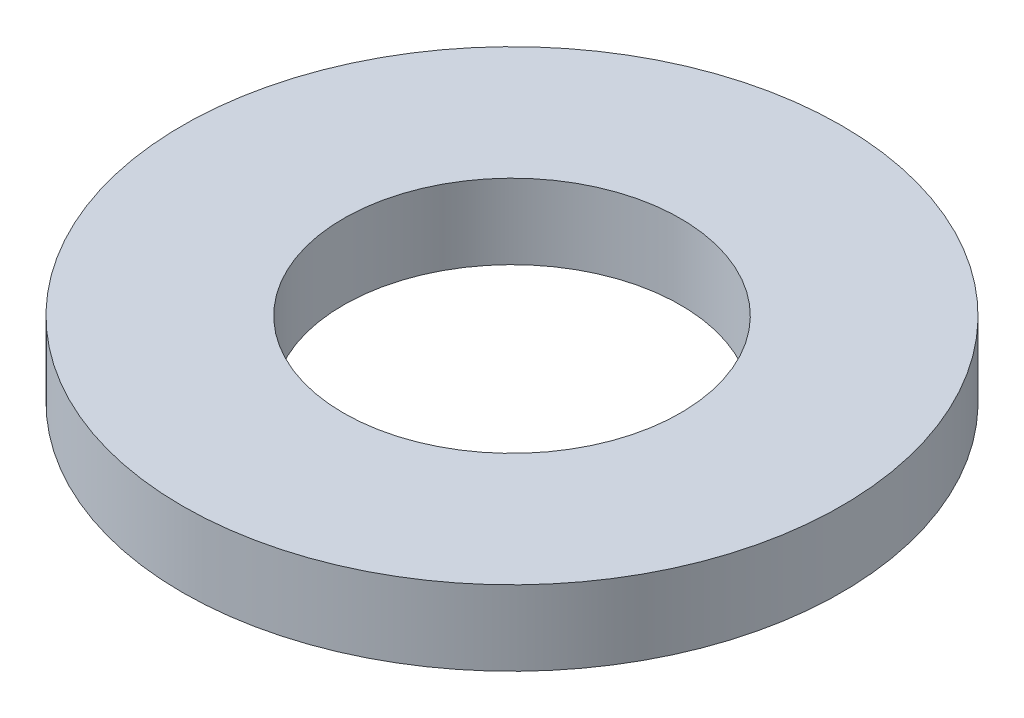
from build123d import *

# Parameters (mm, degrees)
SKETCH_1_R      = 4.4
SKETCH_1_R_2    = 2.25
EXTRUDE_1_DEPTH = 1


with BuildPart() as part:
    # 草图1 → 凸台-拉伸1 (new body)
    with BuildSketch(Plane(origin=(0, 0, 0), x_dir=(1, 0, 0), z_dir=(0, 1, 0))):
        Circle(SKETCH_1_R)
        Circle(SKETCH_1_R_2, mode=Mode.SUBTRACT)
    extrude(amount=EXTRUDE_1_DEPTH)


solid = part.part
